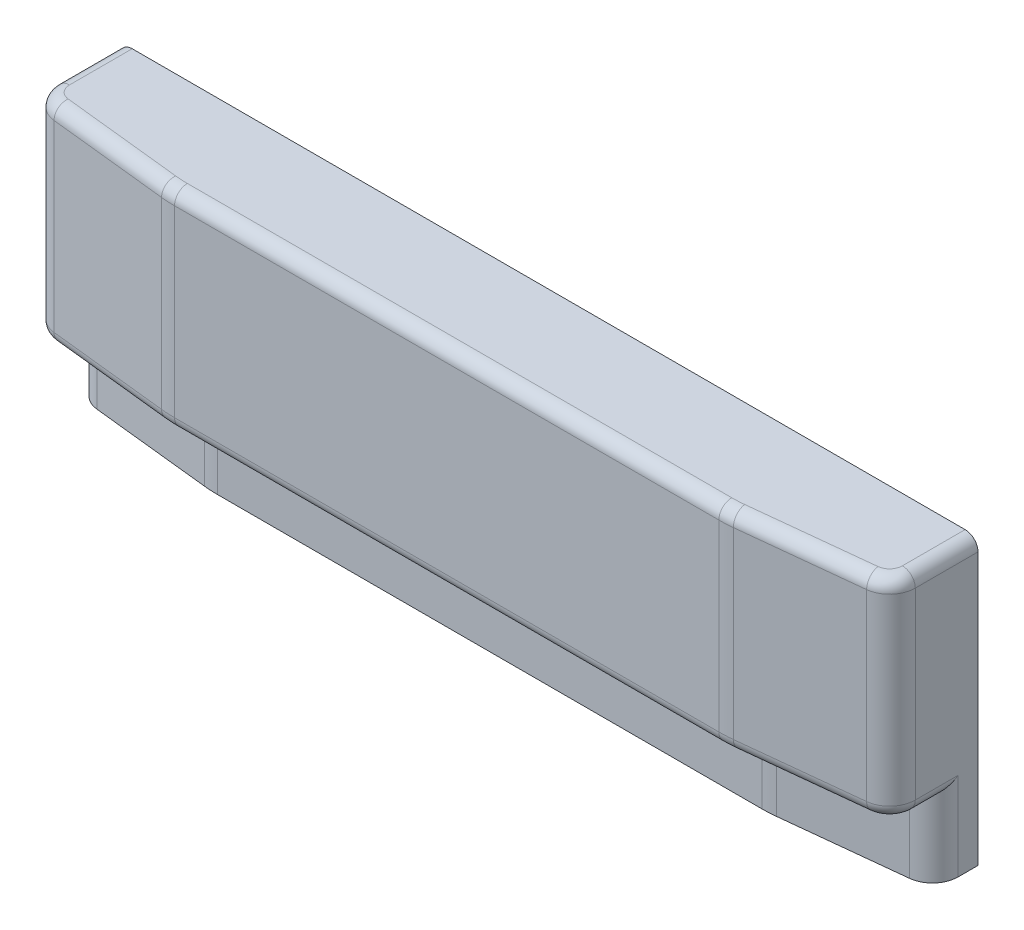
from build123d import *

# Parameters (mm, degrees)
BOSS_EXTRUDE1_DEPTH = 168.275
CUT_EXTRUDE1_DEPTH  = 44.45
FILLET1_R           = 15.24
FILLET2_R           = 76.2
FILLET3_R           = 7.62
FILLET4_R           = 7.62


with BuildPart() as part:
    # Sketch7 → Boss-Extrude1 (new body)
    with BuildSketch(Plane(origin=(0, 0, 0), x_dir=(1, 0, 0), z_dir=(0, 1, 0))):
        Polygon((0, 0), (508, 0), (508, -50.8), (419.1, -60.325), (88.9, -60.325), (0, -50.8), align=None)
    extrude(amount=BOSS_EXTRUDE1_DEPTH)

    # Sketch10 → Cut-Extrude1 (cut)
    with BuildSketch(Plane.XZ):
        Polygon((0, 50.8), (0, 25.4), (88.9, 34.925), (419.1, 34.925), (508, 25.4), (508, 50.8), (419.1, 60.325), (88.9, 60.325), align=None)
    extrude(amount=-CUT_EXTRUDE1_DEPTH, mode=Mode.SUBTRACT)

    # Fillet1
    fillet1_edges = [part.edges().sort_by_distance(p)[0] for p in [
        (508, 106.3625, 50.8),
        (0, 106.3625, 50.8),
        (508, 22.225, 25.4),
        (0, 22.225, 25.4),
    ]]
    fillet(fillet1_edges, radius=FILLET1_R)

    # Fillet2
    fillet2_edges = [part.edges().sort_by_distance(p)[0] for p in [
        (419.1, 106.3625, 60.325),
        (88.9, 106.3625, 60.325),
        (419.1, 22.225, 34.925),
        (88.9, 22.225, 34.925),
    ]]
    fillet(fillet2_edges, radius=FILLET2_R)

    # Fillet3
    fillet3_edges = [part.edges().sort_by_distance(p)[0] for p in [
        (508, 168.275, 18.552816133),
        (0, 168.275, 18.552816133),
        (49.234552732, 168.275, 56.07513065),
        (3.904199904, 168.275, 47.291761863),
        (504.095800096, 168.275, 47.291761863),
        (458.765447268, 168.275, 56.07513065),
        (254, 168.275, 60.325),
        (88.905795265, 168.275, 60.216512154),
        (419.094204735, 168.275, 60.216512154),
    ]]
    fillet(fillet3_edges, radius=FILLET3_R)

    # Fillet4
    fillet4_edges = [part.edges().sort_by_distance(p)[0] for p in [
        (508, 44.45, 18.552816133),
        (0, 44.45, 18.552816133),
        (458.765447268, 44.45, 56.07513065),
        (3.904199904, 44.45, 47.291761863),
        (504.095800096, 44.45, 47.291761863),
        (254, 44.45, 60.325),
        (49.234552732, 44.45, 56.07513065),
        (88.905795265, 44.45, 60.216512154),
        (419.094204735, 44.45, 60.216512154),
    ]]
    fillet(fillet4_edges, radius=FILLET4_R)


solid = part.part
